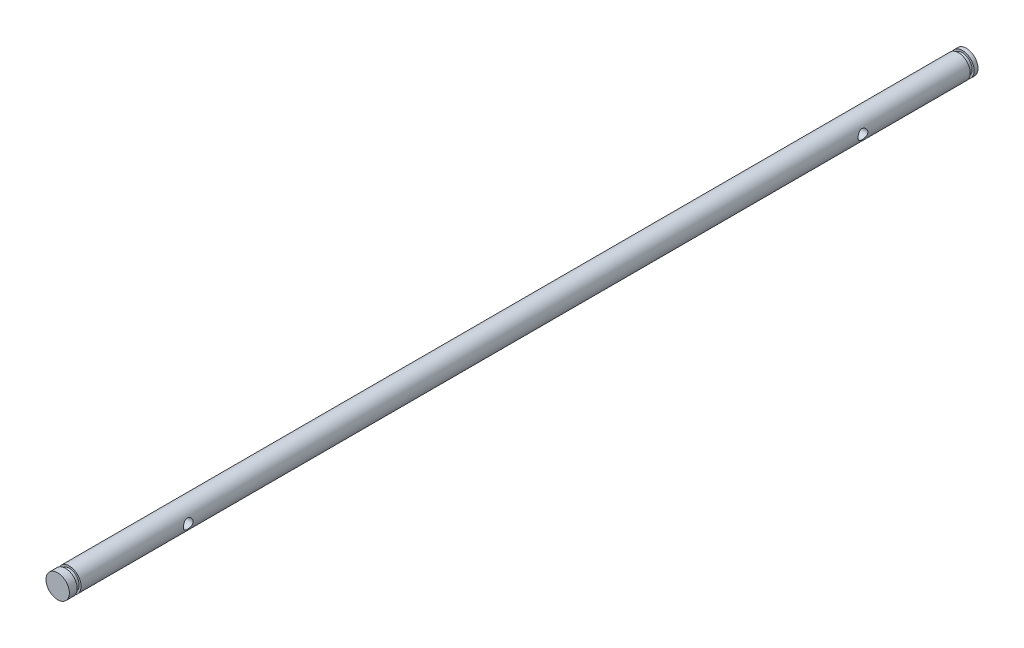
from build123d import *

# Parameters (mm, degrees)
SKETCH1_R           = 3
BOSS_EXTRUDE1_DEPTH = 233
SKETCH2_W           = 0.5
SKETCH2_H           = 1
CUT_EXTRUDE1_DEPTH  = 0.5
M3_TAPPED_HOLE1_D   = 2.5
SKETCH6_W           = 0.5
SKETCH6_H           = 1
BOSS_EXTRUDE2_DEPTH = 0.5


with BuildPart() as part:
    # Sketch1 → Boss-Extrude1 (new body)
    with BuildSketch(Plane.XY):
        Circle(SKETCH1_R)
    extrude(amount=BOSS_EXTRUDE1_DEPTH)

    # Sketch2 → Cut-Revolve1 (revolve, cut)
    with BuildSketch(Plane(origin=(0, 0, 0), x_dir=(1, 0, 0), z_dir=(0, 1, 0))):
        with Locations((2.75, -1.5)):
            Rectangle(SKETCH2_W, SKETCH2_H)
    revolve(axis=Axis((0, 0, 233), (0, 0, -1)), mode=Mode.SUBTRACT)

    # Sketch3 → Cut-Extrude1 (cut)
    with BuildSketch(Plane.XY.offset(233)):
        with BuildLine():
            Line((2.7, 1.307669683), (2.7, -1.307669683))
            ThreePointArc((2.7, -1.307669683), (3, 0), (2.7, 1.307669683))
        make_face()
    extrude(amount=-CUT_EXTRUDE1_DEPTH, mode=Mode.SUBTRACT)

    # M3 Tapped Hole1 (through all)
    with Locations(Plane(origin=(3.7, 0, 29.5), x_dir=(0, 0, 1), z_dir=(1, 0, 0))):
        with Locations((0, 0), (173, 0)):
            Hole(M3_TAPPED_HOLE1_D / 2)

    # Sketch6 → Cut-Revolve2 (revolve, cut)
    with BuildSketch(Plane(origin=(0, 0, 0), x_dir=(1, 0, 0), z_dir=(0, 1, 0))):
        with Locations((2.75, -230.5)):
            Rectangle(SKETCH6_W, SKETCH6_H)
    revolve(axis=Axis((0, 0, 233), (0, 0, -1)), mode=Mode.SUBTRACT)

    # Sketch7 → Boss-Extrude2 (add)
    with BuildSketch(Plane.XY.offset(232.5)):
        with BuildLine():
            Line((2.7, 1.307669683), (2.7, -1.307669683))
            ThreePointArc((2.7, -1.307669683), (3, 0), (2.7, 1.307669683))
        make_face()
    extrude(amount=BOSS_EXTRUDE2_DEPTH)


solid = part.part
